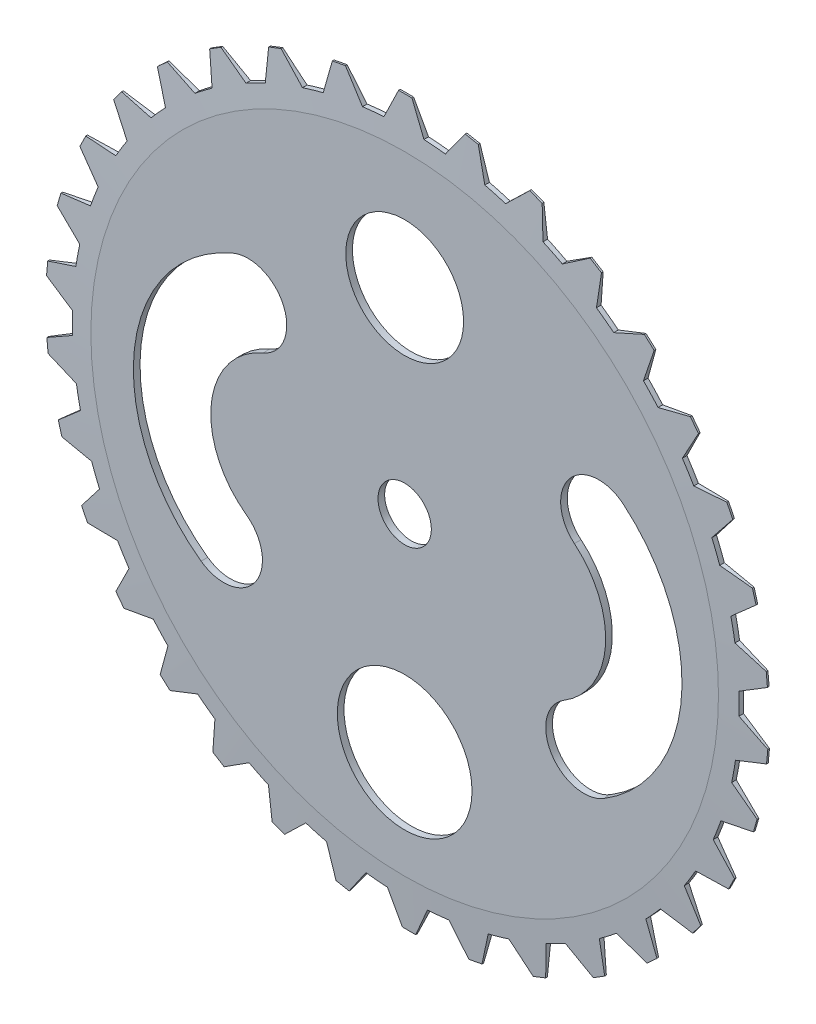
from build123d import *

# Parameters (mm, degrees)
SKETCH1_R           = 63.5
BOSS_EXTRUDE1_DEPTH = 1.27
SKETCH3_R           = 11.218230105
SKETCH3_R_2         = 12.828515613
CUT_EXTRUDE3_DEPTH  = 1.27
SKETCH2_R           = 5.08
CUT_EXTRUDE4_DEPTH  = 1.27
BOSS_EXTRUDE2_DEPTH = 1.27
SKETCH6_OUTSIDE_W   = 226.74
SKETCH6_OUTSIDE_H   = 227.028
SKETCH6_OUTSIDE_R   = 59.771525152
CUT_EXTRUDE7_DEPTH  = 1.27
CUT_EXTRUDE7_TAPER  = 86.999999999


with BuildPart() as part:
    # Sketch1 → Boss-Extrude1 (new body)
    with BuildSketch(Plane.XY):
        Circle(SKETCH1_R)
    extrude(amount=BOSS_EXTRUDE1_DEPTH)

    # Sketch3 → Cut-Extrude3 (cut)
    with BuildSketch(Plane.XY.offset(1.27)):
        with Locations((0, 37.33084012)):
            Circle(SKETCH3_R)
        with Locations((0, -39.310977045)):
            Circle(SKETCH3_R_2)
        with BuildLine():
            ThreePointArc((-32.705617261, 26.657821728), (-51.478812428, 1.516347357), (-38.777198349, -27.175037937))
            ThreePointArc((-38.777198349, -27.175037937), (-28.484696618, -25.509363584), (-30.15037097, -15.216861852))
            ThreePointArc((-30.15037097, -15.216861852), (-36.826538057, -0.136220842), (-26.959052956, 13.078531446))
            ThreePointArc((-26.959052956, 13.078531446), (-23.042689968, 22.741458739), (-32.705617261, 26.657821728))
        make_face()
        with BuildLine():
            ThreePointArc((37.927379706, -27.97986176), (52.742371865, -3.721164391), (41.633179856, 22.442823142))
            ThreePointArc((41.633179856, 22.442823142), (31.391895127, 21.508018477), (32.326699791, 11.266733748))
            ThreePointArc((32.326699791, 11.266733748), (38.237917783, -2.655163875), (30.354837886, -15.563253699))
            ThreePointArc((30.354837886, -15.563253699), (27.932804766, -25.557828639), (37.927379706, -27.97986176))
        make_face()
    extrude(amount=-CUT_EXTRUDE3_DEPTH, mode=Mode.SUBTRACT)

    # Sketch2 → Cut-Extrude4 (cut)
    with BuildSketch(Plane.XY.offset(1.27)):
        Circle(SKETCH2_R)
    extrude(amount=-CUT_EXTRUDE4_DEPTH, mode=Mode.SUBTRACT)

    # Sketch4 → Boss-Extrude2 (add)
    with BuildSketch(Plane.XY.offset(1.27)):
        Polygon((-4.141884677, 63.364775635), (3.478115323, 63.404674227), (0.912694749, 68.831863411), (-0.357305251, 68.831863411), (-1.627305251, 68.831863411), align=None)
        Polygon((7.57188575, 63.046939229), (11.048224425, 67.958886689), (12.296600262, 67.725524802), (13.544976099, 67.492162914), (15.069472117, 61.685987146), align=None)
        Polygon((19.02780469, 60.582114924), (23.34752007, 64.771651589), (24.531759801, 64.312874673), (25.715999533, 63.854097757), (26.147656111, 57.866657756), align=None)
        Polygon((29.835754562, 56.054239356), (34.851743921, 59.378695579), (35.931519683, 58.710126733), (37.011295446, 58.041557886), (36.335413038, 52.07674874), align=None)
        Polygon((39.627683596, 49.617503895), (45.169133432, 51.963669308), (46.107674757, 51.108075841), (47.046216082, 50.252482373), (45.285811052, 44.513428506), align=None)
        Polygon((48.070139394, 41.49110385), (53.94834228, 42.779082603), (54.713688268, 41.765600724), (55.479034256, 40.752118845), (52.694055086, 35.434256851), align=None)
        Polygon((54.875624248, 31.951774025), (60.890405034, 32.137705547), (61.456492746, 31.000848167), (62.022580458, 29.863990787), (58.307866274, 25.148414078), align=None)
        Polygon((59.812385535, 21.324364859), (65.758918075, 20.401917473), (66.106470073, 19.180398906), (66.45402207, 17.95888034), (61.936073008, 14.006172226), align=None)
        Polygon((62.712307769, 9.970780022), (68.388090031, 7.97136657), (68.505270847, 6.706784166), (68.622451664, 5.442201762), (63.455121059, 2.386966977), align=None)
        Polygon((63.476637578, -1.722347769), (68.688387602, -4.730639662), (68.571206786, -5.995222066), (68.454025969, -7.25980447), (62.81328107, -9.31352357), align=None)
        Polygon((62.079346625, -13.356823073), (66.649584517, -17.271549633), (66.30203252, -18.4930682), (65.954480522, -19.714586767), (60.032410129, -20.696853241), align=None)
        Polygon((58.568017979, -24.536447786), (62.341109768, -29.224297697), (61.775022056, -30.361155077), (61.208934345, -31.498012457), (55.207207463, -31.375376399), align=None)
        Polygon((53.062225726, -34.880513199), (55.909683296, -40.181847354), (55.144337308, -41.195329232), (54.37899132, -42.208811111), (48.50198956, -40.985448744), align=None)
        Polygon((45.749463016, -44.036764569), (47.574319616, -49.771052391), (46.635778291, -50.626645858), (45.697236966, -51.482239326), (40.145094574, -49.199810788), align=None)
        Polygon((36.878757214, -51.693396738), (37.61886954, -57.665363933), (36.539093778, -58.33393278), (35.459318015, -59.002501627), (30.421106542, -55.738732285), align=None)
        Polygon((26.752189567, -57.589672281), (26.382353981, -63.595950669), (25.19811425, -64.054727585), (24.013874518, -64.513504501), (19.661164212, -60.379538105), align=None)
        Polygon((15.714608189, -61.524800605), (14.247418999, -67.360853579), (12.999043163, -67.594215467), (11.750667326, -67.827577354), (8.231684516, -62.964191173), align=None)
        Polygon((4.141884677, -63.364775635), (1.627305251, -68.831863411), (0.357305251, -68.831863411), (-0.912694749, -68.831863411), (-3.478115323, -63.404674227), align=None)
        Polygon((-7.57188575, -63.046939229), (-11.048224425, -67.958886689), (-12.296600262, -67.725524802), (-13.544976098, -67.492162914), (-15.069472117, -61.685987146), align=None)
        Polygon((-19.02780469, -60.582114924), (-23.34752007, -64.771651589), (-24.531759801, -64.312874673), (-25.715999533, -63.854097757), (-26.147656111, -57.866657756), align=None)
        Polygon((-29.835754562, -56.054239356), (-34.851743921, -59.378695579), (-35.931519683, -58.710126732), (-37.011295445, -58.041557886), (-36.335413038, -52.07674874), align=None)
        Polygon((-39.627683596, -49.617503895), (-45.169133432, -51.963669308), (-46.107674757, -51.108075841), (-47.046216082, -50.252482373), (-45.285811052, -44.513428506), align=None)
        Polygon((-48.070139394, -41.49110385), (-53.948342279, -42.779082603), (-54.713688268, -41.765600724), (-55.479034256, -40.752118845), (-52.694055086, -35.434256851), align=None)
        Polygon((-54.875624248, -31.951774025), (-60.890405034, -32.137705547), (-61.456492746, -31.000848167), (-62.022580458, -29.863990787), (-58.307866273, -25.148414078), align=None)
        Polygon((-59.812385535, -21.324364859), (-65.758918075, -20.401917473), (-66.106470073, -19.180398906), (-66.45402207, -17.95888034), (-61.936073007, -14.006172226), align=None)
        Polygon((-62.712307769, -9.970780022), (-68.388090031, -7.97136657), (-68.505270847, -6.706784166), (-68.622451664, -5.442201762), (-63.455121059, -2.386966977), align=None)
        Polygon((-63.476637578, 1.722347769), (-68.688387602, 4.730639662), (-68.571206786, 5.995222066), (-68.454025969, 7.25980447), (-62.813281069, 9.31352357), align=None)
        Polygon((-62.079346625, 13.356823073), (-66.649584517, 17.271549633), (-66.30203252, 18.4930682), (-65.954480522, 19.714586767), (-60.032410129, 20.696853241), align=None)
        Polygon((-58.568017979, 24.536447786), (-62.341109768, 29.224297697), (-61.775022056, 30.361155077), (-61.208934344, 31.498012457), (-55.207207463, 31.375376399), align=None)
        Polygon((-53.062225726, 34.880513199), (-55.909683296, 40.181847354), (-55.144337308, 41.195329232), (-54.37899132, 42.208811111), (-48.50198956, 40.985448744), align=None)
        Polygon((-45.749463016, 44.036764569), (-47.574319616, 49.771052391), (-46.635778291, 50.626645859), (-45.697236966, 51.482239326), (-40.145094574, 49.199810788), align=None)
        Polygon((-36.878757214, 51.693396738), (-37.61886954, 57.665363933), (-36.539093778, 58.33393278), (-35.459318015, 59.002501627), (-30.421106542, 55.738732285), align=None)
        Polygon((-26.752189566, 57.589672281), (-26.382353981, 63.595950669), (-25.19811425, 64.054727585), (-24.013874518, 64.513504501), (-19.661164212, 60.379538105), align=None)
        Polygon((-15.714608189, 61.524800605), (-14.247418999, 67.360853579), (-12.999043162, 67.594215467), (-11.750667326, 67.827577354), (-8.231684516, 62.964191173), align=None)
    extrude(amount=-BOSS_EXTRUDE2_DEPTH)

    # Sketch6 outside → Cut-Extrude7 (cut)
    with BuildSketch(Plane.XY.offset(1.27)):
        Rectangle(SKETCH6_OUTSIDE_W, SKETCH6_OUTSIDE_H)
        Circle(SKETCH6_OUTSIDE_R, mode=Mode.SUBTRACT)
    cut_extrude7 = extrude(amount=-CUT_EXTRUDE7_DEPTH, taper=CUT_EXTRUDE7_TAPER, mode=Mode.SUBTRACT)

    # Mirror1: Cut-Extrude7 across plane
    add(cut_extrude7.mirror(Plane.XY.offset(0.635)), mode=Mode.SUBTRACT)


solid = part.part
